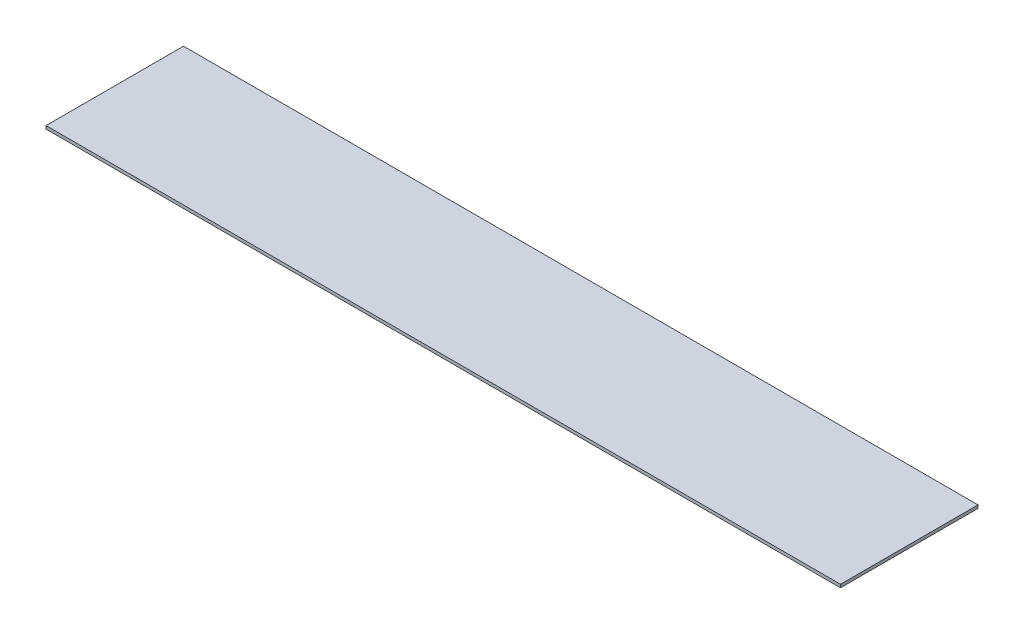
from build123d import *

# Parameters (mm, degrees)
SKETCH1_W           = 260
SKETCH1_H           = 45
BOSS_EXTRUDE1_DEPTH = 1


with BuildPart() as part:
    # Sketch1 → Boss-Extrude1 (new body)
    with BuildSketch(Plane(origin=(0, 0, 0), x_dir=(1, 0, 0), z_dir=(0, 1, 0))):
        with Locations((-21.496062992, 77.200787402)):
            Rectangle(SKETCH1_W, SKETCH1_H)
    extrude(amount=BOSS_EXTRUDE1_DEPTH)


solid = part.part
